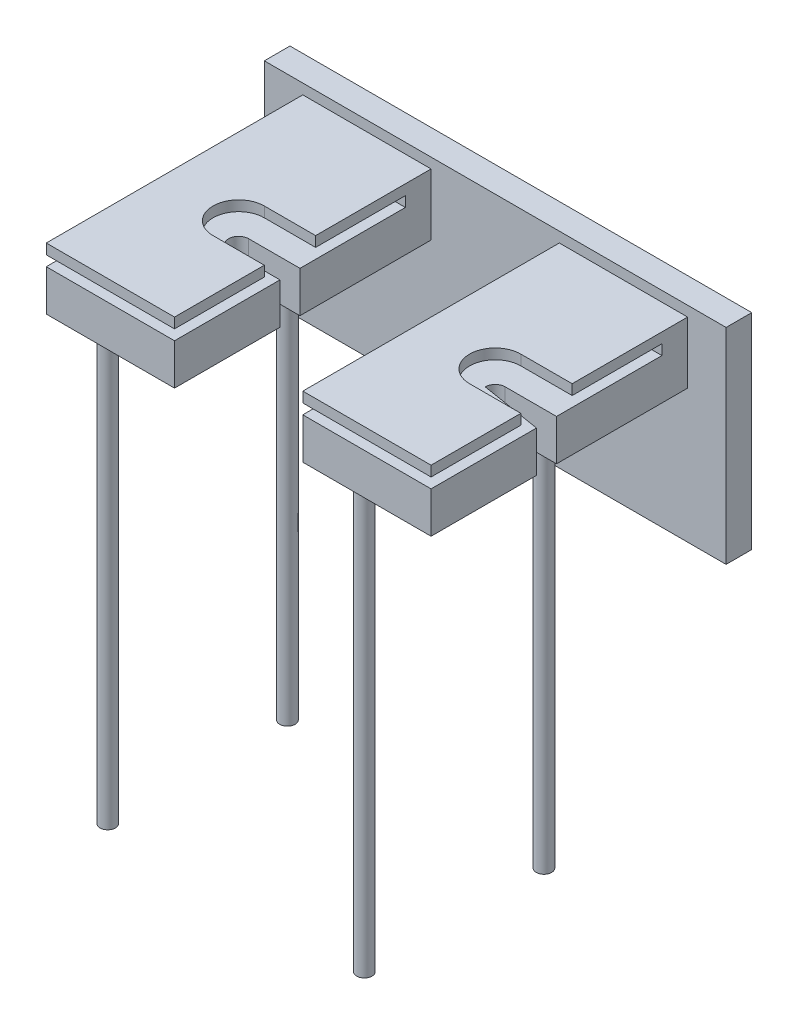
from build123d import *

# Parameters (mm, degrees)
SKETCH1_W             = 25
SKETCH1_H             = 12
BOSS_EXTRUDE1_DEPTH   = 50
SKETCH2_W             = 25
SKETCH2_H             = 2
CUT_EXTRUDE1_DEPTH    = 45
SKETCH4_R             = 1.4224
CUT_EXTRUDE2_DEPTH    = 8
CUT_EXTRUDE3_DEPTH    = 2
LPATTERN1_COUNT       = 2
LPATTERN1_PITCH       = 50
SKETCH7_W             = 90
SKETCH7_H             = 40
BOSS_EXTRUDE2_DEPTH   = 5
CUT_EXTRUDE4_START    = -55
SKETCH8_R             = 1.4224
CUT_EXTRUDE4_DEPTH    = 10
CUT_EXTRUDE5_START    = -55
SKETCH9_R             = 1.4224
CUT_EXTRUDE5_DEPTH    = 10
BOSS_EXTRUDE3_START   = -7
SKETCH10_R            = 1.5
BOSS_EXTRUDE3_DEPTH   = 90
BOSS_EXTRUDE3_2_DEPTH = 90
CUT_EXTRUDE6_START    = -7
SKETCH10_3_R          = 1.5
CUT_EXTRUDE6_DEPTH    = 5
BOSS_EXTRUDE4_START   = -7
SKETCH11_R            = 1.5
BOSS_EXTRUDE4_DEPTH   = 90
BOSS_EXTRUDE4_2_DEPTH = 90
CUT_EXTRUDE7_START    = -7
SKETCH11_5_R          = 1.5
CUT_EXTRUDE7_DEPTH    = 5
CUT_EXTRUDE8_START    = -12
CUT_EXTRUDE8_DEPTH    = 8
CUT_EXTRUDE9_START    = -12
CUT_EXTRUDE9_DEPTH    = 8


with BuildPart() as part:
    # Sketch1 → Boss-Extrude1 (new body)
    with BuildSketch(Plane.XY):
        with Locations((-50.784177629, 2.145908792)):
            Rectangle(SKETCH1_W, SKETCH1_H)
    extrude(amount=BOSS_EXTRUDE1_DEPTH)

    # Sketch2 → Cut-Extrude1 (cut)
    with BuildSketch(Plane.XY.offset(50)):
        with Locations((-50.784177629, 5.145908792)):
            Rectangle(SKETCH2_W, SKETCH2_H)
    extrude(amount=-CUT_EXTRUDE1_DEPTH, mode=Mode.SUBTRACT)

    # Sketch4 → Cut-Extrude2 (cut)
    with BuildSketch(Plane.XZ.offset(3.854091208)):
        with Locations((-50.784177629, 37)):
            Circle(SKETCH4_R)
    extrude(amount=-CUT_EXTRUDE2_DEPTH, mode=Mode.SUBTRACT)

    # Sketch6 → Cut-Extrude3 (cut)
    with BuildSketch(Plane.XZ.offset(-6.145908792)):
        with BuildLine():
            Line((-38.284177629, 32.5), (-48.284177629, 32.5))
            ThreePointArc((-48.284177629, 32.5), (-44.748643723, 31.035533906), (-43.284177629, 27.5))
            ThreePointArc((-43.284177629, 27.5), (-44.748643723, 23.964466094), (-48.284177629, 22.5))
            Line((-48.284177629, 22.5), (-38.284177629, 22.5))
            Line((-38.284177629, 22.5), (-38.284177629, 32.5))
        make_face()
        with BuildLine():
            ThreePointArc((-43.284177629, 27.5), (-44.748643723, 31.035533906), (-48.284177629, 32.5))
            Line((-48.284177629, 32.5), (-48.284177629, 22.5))
            ThreePointArc((-48.284177629, 22.5), (-44.748643723, 23.964466094), (-43.284177629, 27.5))
        make_face()
        with BuildLine():
            Line((-48.284177629, 22.5), (-48.284177629, 32.5))
            ThreePointArc((-48.284177629, 32.5), (-53.284177629, 27.5), (-48.284177629, 22.5))
        make_face()
    extrude(amount=-CUT_EXTRUDE3_DEPTH, mode=Mode.SUBTRACT)


with BuildPart() as lpattern1_1:
    # LPattern1: pattern copy
    add(part.part.moved(Location(Vector(1, 0, 0) * (1 * LPATTERN1_PITCH))))


with BuildPart() as body_3:
    # Sketch7 → Boss-Extrude2 (new body)
    with BuildSketch(Plane(origin=(0, 0, 0), x_dir=(-1, 0, 0), z_dir=(0, 0, -1))):
        with Locations((25.784177629, -9.854091208)):
            Rectangle(SKETCH7_W, SKETCH7_H)
    extrude(amount=BOSS_EXTRUDE2_DEPTH)


with BuildPart() as cut_extrude4_tool:
    # Sketch8 → Cut-Extrude4 (new body)
    with BuildSketch(Plane.XY.offset(50).offset(CUT_EXTRUDE4_START)):
        with Locations((-59.284177629, 0)):
            Circle(SKETCH8_R)
        with Locations((-42.284177629, 0)):
            Circle(SKETCH8_R)
    extrude(amount=CUT_EXTRUDE4_DEPTH)


with BuildPart() as part_1:
    add(part.part)

    # Cut-Extrude4: cut by cut_extrude4_tool
    add(cut_extrude4_tool.part, mode=Mode.SUBTRACT)

    # Sketch10_3 → Cut-Extrude6 (cut)
    with BuildSketch(Plane(origin=(0, 8.145908792, 0), x_dir=(1, 0, 0), z_dir=(0, 1, 0)).offset(CUT_EXTRUDE6_START)):
        with Locations((-56.284177629, -10)):
            Circle(SKETCH10_3_R)
        with Locations((-56.302755809, -45)):
            Circle(SKETCH10_3_R)
    extrude(amount=-CUT_EXTRUDE6_DEPTH, mode=Mode.SUBTRACT)

    # Sketch12 → Cut-Extrude8 (cut)
    with BuildSketch(Plane(origin=(0, 8.145908792, 0), x_dir=(1, 0, 0), z_dir=(0, 1, 0)).offset(CUT_EXTRUDE8_START)):
        with BuildLine():
            Line((-38.284177629, -25.55), (-48.284177629, -25.55))
            ThreePointArc((-48.284177629, -25.55), (-46.905319405, -26.121141777), (-46.334177629, -27.5))
            ThreePointArc((-46.334177629, -27.5), (-46.905319405, -28.878858223), (-48.284177629, -29.45))
            Line((-48.284177629, -29.45), (-38.284177629, -29.45))
            Line((-38.284177629, -29.45), (-38.284177629, -25.55))
        make_face()
        with BuildLine():
            ThreePointArc((-46.334177629, -27.5), (-46.905319405, -26.121141777), (-48.284177629, -25.55))
            Line((-48.284177629, -25.55), (-48.284177629, -29.45))
            ThreePointArc((-48.284177629, -29.45), (-46.905319405, -28.878858223), (-46.334177629, -27.5))
        make_face()
        with BuildLine():
            Line((-48.284177629, -29.45), (-48.284177629, -25.55))
            ThreePointArc((-48.284177629, -25.55), (-50.234177629, -27.5), (-48.284177629, -29.45))
        make_face()
    extrude(amount=CUT_EXTRUDE8_DEPTH, mode=Mode.SUBTRACT)


with BuildPart() as body_3_1:
    add(body_3.part)

    # Cut-Extrude4: cut by cut_extrude4_tool
    add(cut_extrude4_tool.part, mode=Mode.SUBTRACT)


with BuildPart() as cut_extrude5_tool:
    # Sketch9 → Cut-Extrude5 (new body)
    with BuildSketch(Plane.XY.offset(50).offset(CUT_EXTRUDE5_START)):
        with Locations((-9.284177629, 0)):
            Circle(SKETCH9_R)
        with Locations((7.715822371, 0)):
            Circle(SKETCH9_R)
    extrude(amount=CUT_EXTRUDE5_DEPTH)


with BuildPart() as lpattern1_1_1:
    add(lpattern1_1.part)

    # Cut-Extrude5: cut by cut_extrude5_tool
    add(cut_extrude5_tool.part, mode=Mode.SUBTRACT)

    # Sketch11_5 → Cut-Extrude7 (cut)
    with BuildSketch(Plane(origin=(0, 8.145908792, 0), x_dir=(1, 0, 0), z_dir=(0, 1, 0)).offset(CUT_EXTRUDE7_START)):
        with Locations((-6.284177629, -10)):
            Circle(SKETCH11_5_R)
        with Locations((-6.284177629, -45)):
            Circle(SKETCH11_5_R)
    extrude(amount=-CUT_EXTRUDE7_DEPTH, mode=Mode.SUBTRACT)

    # Sketch13 → Cut-Extrude9 (cut)
    with BuildSketch(Plane(origin=(0, 8.145908792, 0), x_dir=(1, 0, 0), z_dir=(0, 1, 0)).offset(CUT_EXTRUDE9_START)):
        with BuildLine():
            Line((11.715822371, -25.55), (1.715822371, -25.55))
            ThreePointArc((1.715822371, -25.55), (3.094680595, -26.121141777), (3.665822371, -27.5))
            ThreePointArc((3.665822371, -27.5), (3.640329438, -27.814281006), (3.564517191, -28.120344633))
            Line((3.564517191, -28.120344633), (11.715822371, -29.45))
            Line((11.715822371, -29.45), (11.715822371, -25.55))
        make_face()
        with BuildLine():
            ThreePointArc((3.665822371, -27.5), (3.094680595, -26.121141777), (1.715822371, -25.55))
            Line((1.715822371, -25.55), (-0.234177505, -27.500694813))
            Line((-0.234177505, -27.500694813), (3.564517191, -28.120344633))
            ThreePointArc((3.564517191, -28.120344633), (3.640329438, -27.814281006), (3.665822371, -27.5))
        make_face()
        with BuildLine():
            Line((-0.234177505, -27.500694813), (1.715822371, -25.55))
            ThreePointArc((1.715822371, -25.55), (0.336718516, -26.121387452), (-0.234177505, -27.500694813))
        make_face()
    extrude(amount=CUT_EXTRUDE9_DEPTH, mode=Mode.SUBTRACT)


with BuildPart() as body_3_2:
    add(body_3_1.part)

    # Cut-Extrude5: cut by cut_extrude5_tool
    add(cut_extrude5_tool.part, mode=Mode.SUBTRACT)


with BuildPart() as body_4:
    # Sketch10 → Boss-Extrude3 (new body)
    with BuildSketch(Plane(origin=(0, 8.145908792, 0), x_dir=(1, 0, 0), z_dir=(0, 1, 0)).offset(BOSS_EXTRUDE3_START)):
        with Locations((-56.284177629, -10)):
            Circle(SKETCH10_R)
    extrude(amount=-BOSS_EXTRUDE3_DEPTH)


with BuildPart() as body_5:
    # Sketch10 → Boss-Extrude3 2 (new body)
    with BuildSketch(Plane(origin=(0, 8.145908792, 0), x_dir=(1, 0, 0), z_dir=(0, 1, 0)).offset(BOSS_EXTRUDE3_START)):
        with Locations((-56.302755809, -45)):
            Circle(SKETCH10_R)
    extrude(amount=-BOSS_EXTRUDE3_2_DEPTH)


with BuildPart() as body_6:
    # Sketch11 → Boss-Extrude4 (new body)
    with BuildSketch(Plane(origin=(0, 8.145908792, 0), x_dir=(1, 0, 0), z_dir=(0, 1, 0)).offset(BOSS_EXTRUDE4_START)):
        with Locations((-6.284177629, -10)):
            Circle(SKETCH11_R)
    extrude(amount=-BOSS_EXTRUDE4_DEPTH)


with BuildPart() as body_7:
    # Sketch11 → Boss-Extrude4 2 (new body)
    with BuildSketch(Plane(origin=(0, 8.145908792, 0), x_dir=(1, 0, 0), z_dir=(0, 1, 0)).offset(BOSS_EXTRUDE4_START)):
        with Locations((-6.284177629, -45)):
            Circle(SKETCH11_R)
    extrude(amount=-BOSS_EXTRUDE4_2_DEPTH)


solid = Compound([part_1.part, lpattern1_1_1.part, body_3_2.part, body_4.part, body_5.part, body_6.part, body_7.part])
